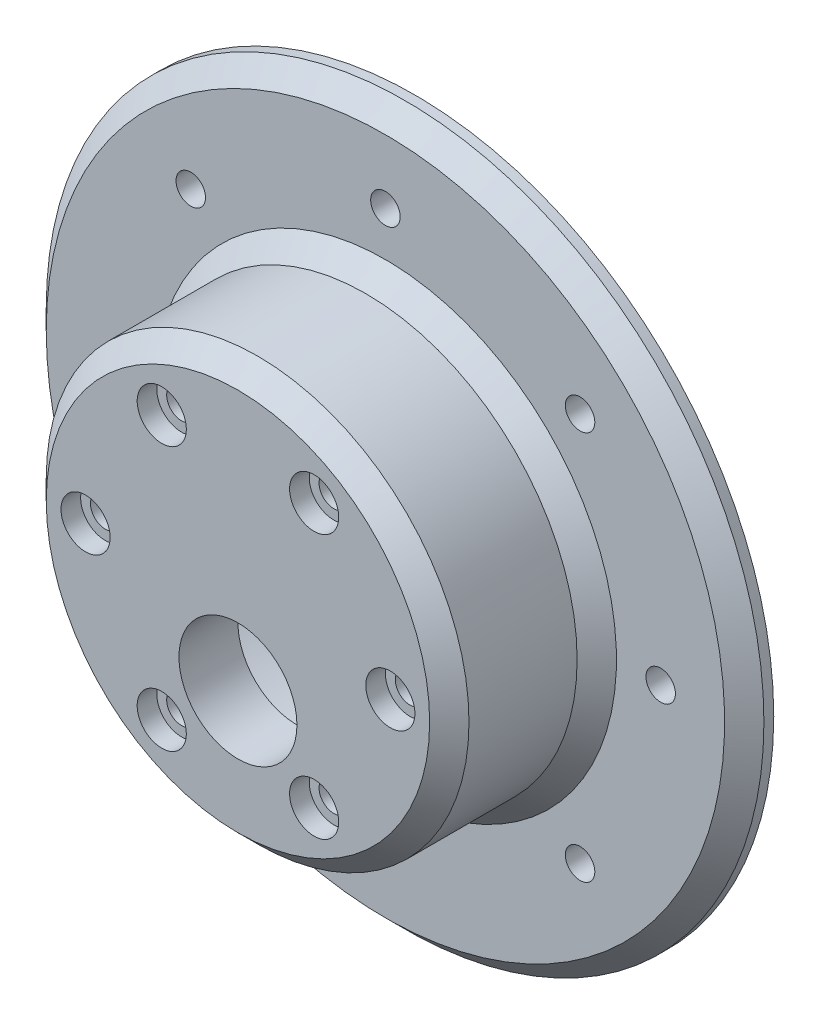
from build123d import *

# Parameters (mm, degrees)
CBORE_FOR_M1_6_HEX_HEAD_CAP_SCREW1_D           = 3
CBORE_FOR_M1_6_HEX_HEAD_CAP_SCREW1_CBORE_D     = 5
CBORE_FOR_M1_6_HEX_HEAD_CAP_SCREW1_CBORE_DEPTH = 2
CIRPATTERN1_COUNT                              = 6
F_12_0MM_DOWEL_HOLE1_D                         = 12
F_12_0MM_DOWEL_HOLE1_DEPTH                     = 15
F_12_0MM_DOWEL_HOLE1_TIP                       = 3.605163714
CHAMFER1_SIZE                                  = 2
CIRPATTERN2_COUNT                              = 8


with BuildPart() as part:
    # Sketch1 → Revolve1 (revolve)
    with BuildSketch(Plane(origin=(0, 0, 0), x_dir=(0, 0, -1), z_dir=(1, 0, 0))):
        Polygon((0, 0), (0, 18.5), (12, 18.5), (12, 23.5), (11, 23.5), (11, 25.5), (12, 25.5), (12, 36.5), (9, 36.5), (9, 21.5), (-6, 21.5), (-6, 0), align=None)
    revolve(axis=Axis((0, 0, 6), (0, 0, -1)))

    # CBORE for M1.6 Hex Head Cap Screw1 (through all)
    with Locations(Plane.XY.offset(6)):
        with Locations((15.5, 0)):
            cbore_for_m1_6_hex_head_cap_screw1 = CounterBoreHole(CBORE_FOR_M1_6_HEX_HEAD_CAP_SCREW1_D / 2, CBORE_FOR_M1_6_HEX_HEAD_CAP_SCREW1_CBORE_D / 2, CBORE_FOR_M1_6_HEX_HEAD_CAP_SCREW1_CBORE_DEPTH)

    # CirPattern1: CBORE for M1.6 Hex Head Cap Screw1 ×6 about axis
    cirpattern1_axis = Axis((0, 0, 0), (0, 0, 1))
    for i in range(1, CIRPATTERN1_COUNT):
        add(cbore_for_m1_6_hex_head_cap_screw1.rotate(cirpattern1_axis, i * 360 / CIRPATTERN1_COUNT), mode=Mode.SUBTRACT)

    # Ø12.0mm Dowel Hole1
    with Locations(Plane.XY.offset(6)):
        with Locations((0, -7)):
            Hole(F_12_0MM_DOWEL_HOLE1_D / 2, depth=F_12_0MM_DOWEL_HOLE1_DEPTH)
            with Locations((0, 0, -(F_12_0MM_DOWEL_HOLE1_DEPTH + F_12_0MM_DOWEL_HOLE1_TIP / 2))):  # 118° drill point
                Cone(0, F_12_0MM_DOWEL_HOLE1_D / 2, F_12_0MM_DOWEL_HOLE1_TIP, mode=Mode.SUBTRACT)

    # Chamfer1
    chamfer1_edges = [part.edges().sort_by_distance(p)[0] for p in [
        (0, -21.5, 6),
        (0, -21.5, -9),
        (0, -36.5, -9),
    ]]
    chamfer(chamfer1_edges, length=CHAMFER1_SIZE)

    # Sketch7 → Ø3.0mm Dowel Hole3 (revolve, cut)
    with BuildSketch(Plane(origin=(0, 28, -9), x_dir=(0, -1, 0), z_dir=(1, 0, 0))):
        Polygon((0, 0), (0, 15.901290929), (1.5, 15), (1.5, 0), align=None)
    f_3_0mm_dowel_hole3 = revolve(axis=Axis((0, 28, -2.65), (0, 0, -1)), mode=Mode.SUBTRACT)

    # CirPattern2: Ø3.0mm Dowel Hole3 ×8 about axis
    cirpattern2_axis = Axis((0, 0, 0), (0, 0, 1))
    for i in range(1, CIRPATTERN2_COUNT):
        add(f_3_0mm_dowel_hole3.rotate(cirpattern2_axis, i * 360 / CIRPATTERN2_COUNT), mode=Mode.SUBTRACT)


solid = part.part
